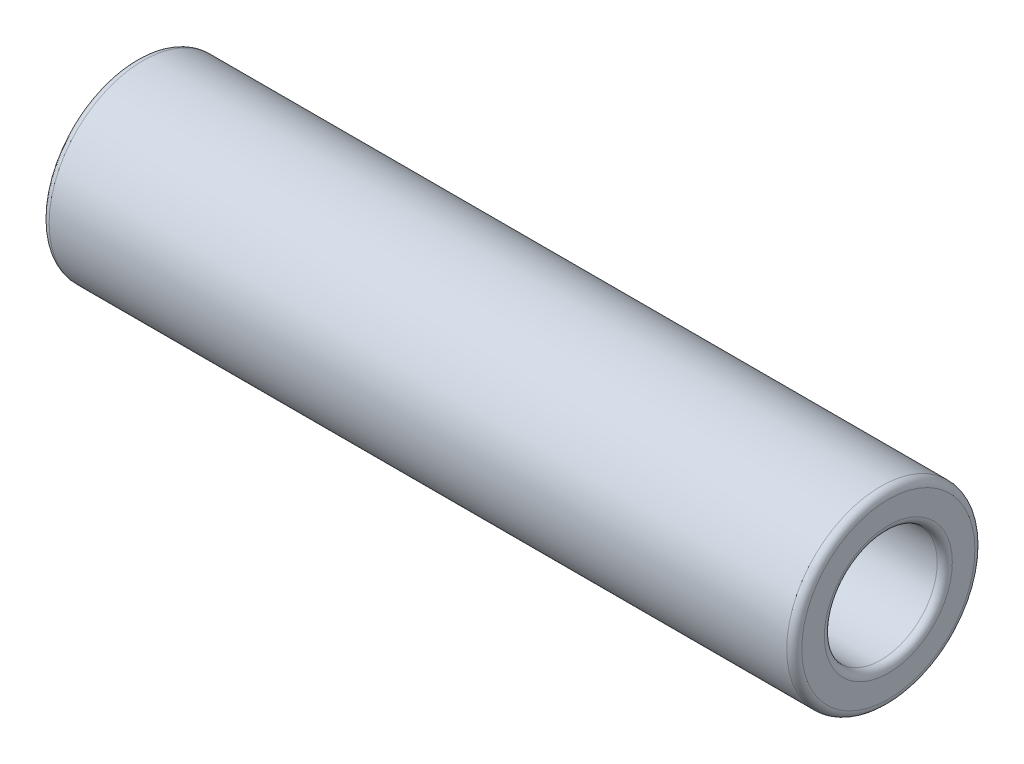
from build123d import *

# Parameters (mm, degrees)
SKETCH1_R           = 158.75
SKETCH1_R_2         = 95.25
BOSS_EXTRUDE1_DEPTH = 1270
FILLET1_R           = 12.7
FILLET2_R           = 12.7


with BuildPart() as part:
    # Sketch1 → Boss-Extrude1 (new body)
    with BuildSketch(Plane(origin=(0, 0, 0), x_dir=(0, 0, -1), z_dir=(1, 0, 0))):
        Circle(SKETCH1_R)
        Circle(SKETCH1_R_2, mode=Mode.SUBTRACT)
    extrude(amount=BOSS_EXTRUDE1_DEPTH)

    # Fillet1
    fillet1_edges = [part.edges().sort_by_distance(p)[0] for p in [
        (1270, 0, 158.75),
        (1270, 0, 95.25),
    ]]
    fillet(fillet1_edges, radius=FILLET1_R)

    # Fillet2
    fillet2_edges = [part.edges().sort_by_distance(p)[0] for p in [
        (0, 0, 158.75),
        (0, 0, 95.25),
    ]]
    fillet(fillet2_edges, radius=FILLET2_R)


solid = part.part
